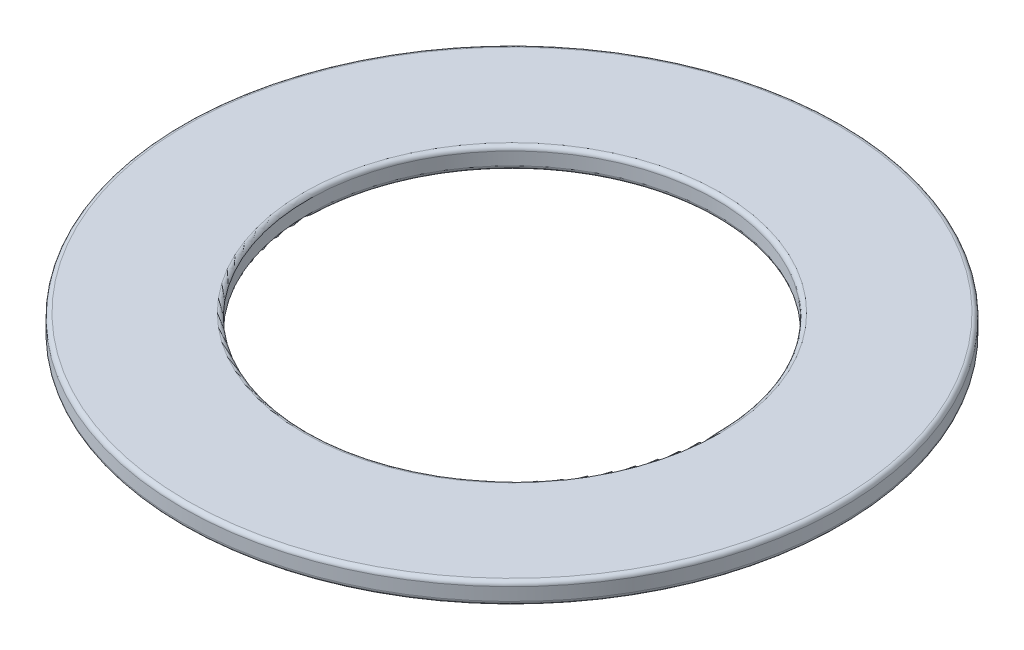
from build123d import *

# Parameters (mm, degrees)
SKETCH2_R           = 7.75
SKETCH2_R_2         = 4.8
BOSS_EXTRUDE1_DEPTH = 0.5
FILLET1_R           = 0.1


with BuildPart() as part:
    # Sketch2 → Boss-Extrude1 (new body)
    with BuildSketch(Plane(origin=(0, 0, 0), x_dir=(1, 0, 0), z_dir=(0, 1, 0))):
        Circle(SKETCH2_R)
        Circle(SKETCH2_R_2, mode=Mode.SUBTRACT)
    extrude(amount=BOSS_EXTRUDE1_DEPTH)

    # Fillet1
    fillet1_edges = [part.edges().sort_by_distance(p)[0] for p in [
        (-7.75, 0, 0),
        (-7.75, 0.5, 0),
        (-4.8, 0, 0),
        (-4.8, 0.5, 0),
    ]]
    fillet(fillet1_edges, radius=FILLET1_R)


solid = part.part
